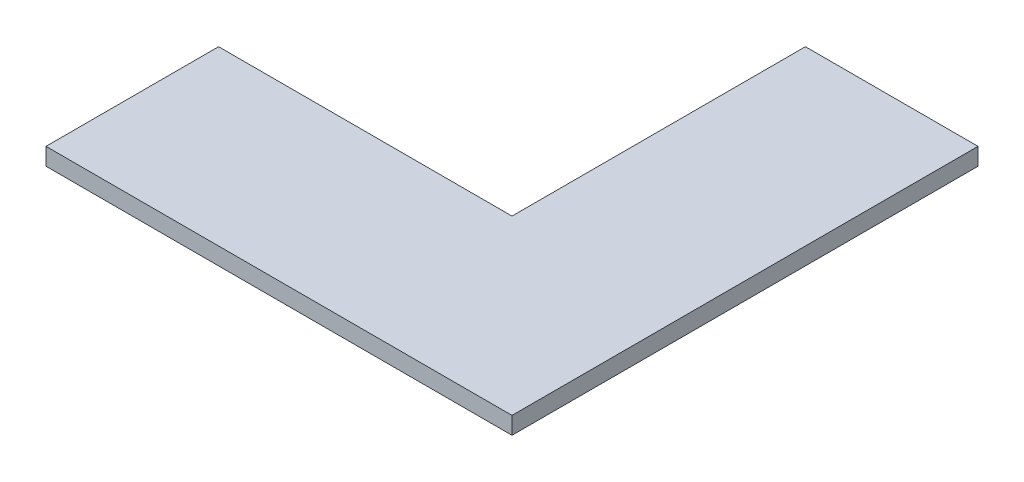
from build123d import *

# Parameters (mm, degrees)
BOSS_EXTRUDE1_DEPTH = 10


with BuildPart() as part:
    # Sketch1 → Boss-Extrude1 (new body)
    with BuildSketch(Plane(origin=(0, 0, 0), x_dir=(1, 0, 0), z_dir=(0, 1, 0))):
        Polygon((-135, -135), (135, -135), (135, 135), (35, 135), (35, -35), (-135, -35), align=None)
    extrude(amount=BOSS_EXTRUDE1_DEPTH)


solid = part.part
